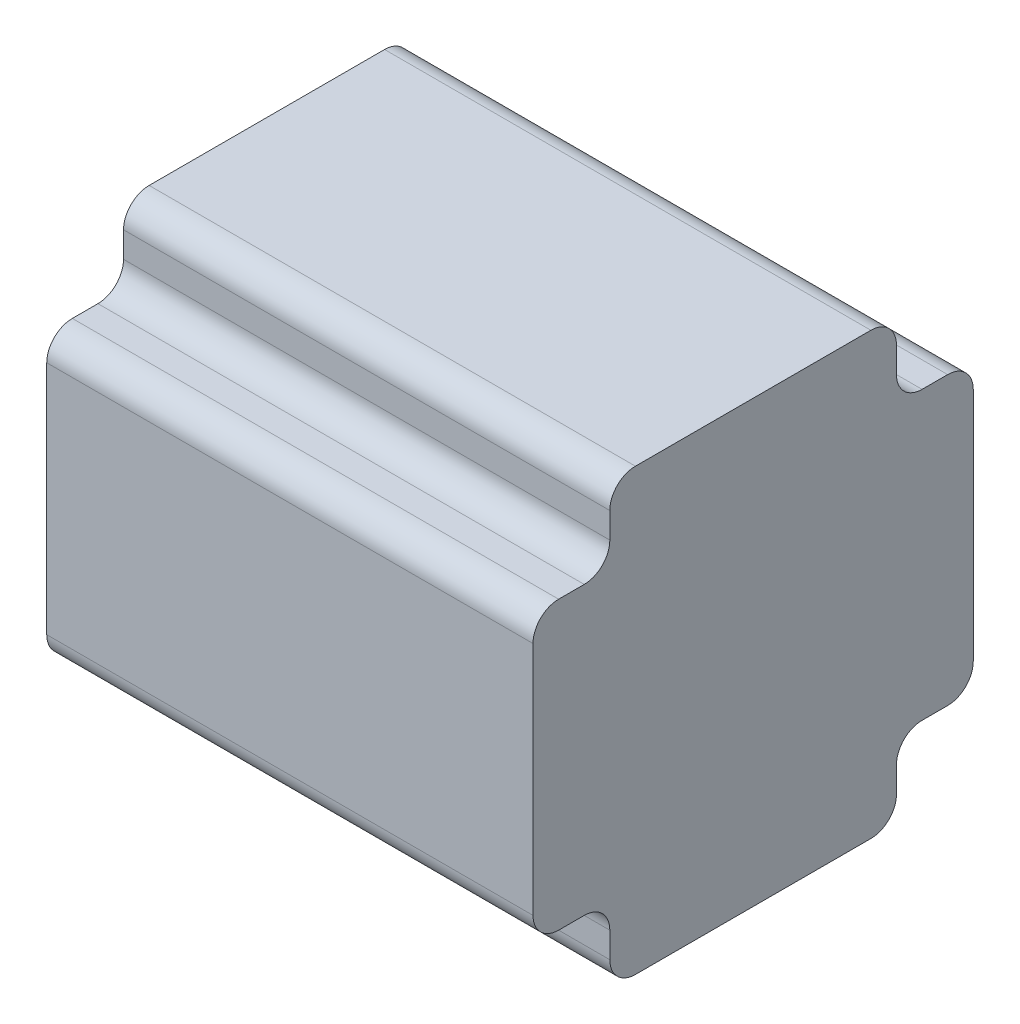
from build123d import *

# Parameters (mm, degrees)
BOSS_EXTRUDE1_DEPTH = 95


with BuildPart() as part:
    # Sketch1 → Boss-Extrude1 (new body)
    with BuildSketch(Plane(origin=(0, 0, 0), x_dir=(0, 0, -1), z_dir=(1, 0, 0))):
        with BuildLine():
            Line((15, 81), (15, 76))
            ThreePointArc((15, 76), (13.535533906, 72.464466094), (10, 71))
            Line((10, 71), (5, 71))
            ThreePointArc((5, 71), (1.464466094, 69.535533906), (0, 66))
            Line((0, 66), (0, 20))
            ThreePointArc((0, 20), (1.464466094, 16.464466094), (5, 15))
            Line((5, 15), (10, 15))
            ThreePointArc((10, 15), (13.535533906, 13.535533906), (15, 10))
            Line((15, 10), (15, 5))
            ThreePointArc((15, 5), (16.464466094, 1.464466094), (20, 0))
            Line((20, 0), (66, 0))
            ThreePointArc((66, 0), (69.535533906, 1.464466094), (71, 5))
            Line((71, 5), (71, 10))
            ThreePointArc((71, 10), (72.464466094, 13.535533906), (76, 15))
            Line((76, 15), (81, 15))
            ThreePointArc((81, 15), (84.535533906, 16.464466094), (86, 20))
            Line((86, 20), (86, 66))
            ThreePointArc((86, 66), (84.535533906, 69.535533906), (81, 71))
            Line((81, 71), (76, 71))
            ThreePointArc((76, 71), (72.464466094, 72.464466094), (71, 76))
            Line((71, 76), (71, 81))
            ThreePointArc((71, 81), (69.535533906, 84.535533906), (66, 86))
            Line((66, 86), (20, 86))
            ThreePointArc((20, 86), (16.464466094, 84.535533906), (15, 81))
        make_face()
    extrude(amount=BOSS_EXTRUDE1_DEPTH)


solid = part.part
